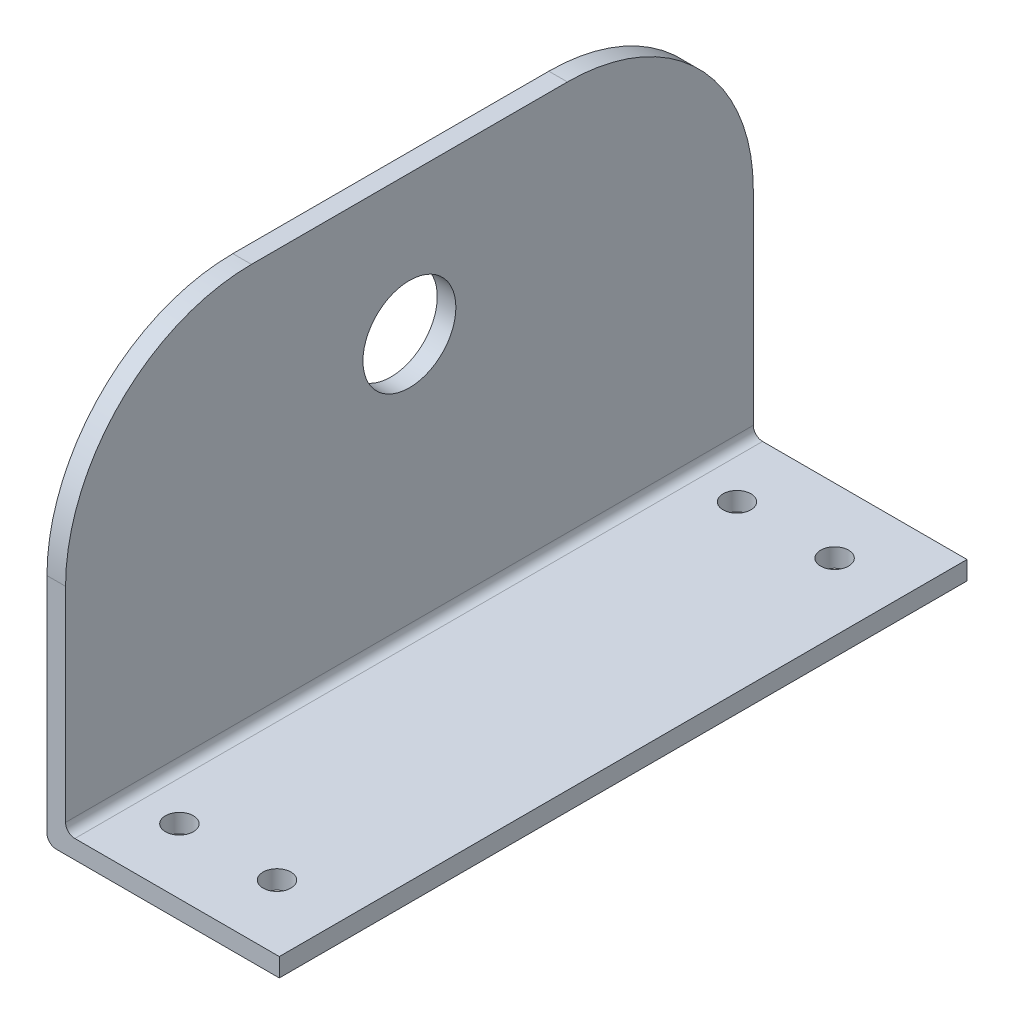
from build123d import *

# Parameters (mm, degrees)
SKETCH1_W           = 23
SKETCH1_H           = 74
SKETCH1_R           = 1.5
BOSS_EXTRUDE1_DEPTH = 2
SKETCH1_3_W         = 2
SKETCH1_3_H         = 74
BOSS_EXTRUDE2_DEPTH = 45
FILLET1_R           = 1
FILLET2_R           = 20
SKETCH2_R           = 5
CUT_EXTRUDE1_DEPTH  = 2


with BuildPart() as part:
    # Sketch1 → Boss-Extrude1 (new body)
    with BuildSketch(Plane(origin=(0, 0, 0), x_dir=(1, 0, 0), z_dir=(0, 1, 0))):
        with Locations((13.5, 37)):
            Rectangle(SKETCH1_W, SKETCH1_H)
        with Locations((7.25, 7)):
            Circle(SKETCH1_R, mode=Mode.SUBTRACT)
        with Locations((17.75, 7)):
            Circle(SKETCH1_R, mode=Mode.SUBTRACT)
        with Locations((7.25, 67)):
            Circle(SKETCH1_R, mode=Mode.SUBTRACT)
        with Locations((17.75, 67)):
            Circle(SKETCH1_R, mode=Mode.SUBTRACT)
    extrude(amount=BOSS_EXTRUDE1_DEPTH)

    # Sketch1_3 → Boss-Extrude2 (add)
    with BuildSketch(Plane(origin=(0, 0, 0), x_dir=(1, 0, 0), z_dir=(0, 1, 0))):
        with Locations((1, 37)):
            Rectangle(SKETCH1_3_W, SKETCH1_3_H)
    extrude(amount=BOSS_EXTRUDE2_DEPTH)

    # Fillet1
    fillet1_edges = [part.edges().sort_by_distance(p)[0] for p in [
        (0, 0, -37),
        (2, 2, -37),
    ]]
    fillet(fillet1_edges, radius=FILLET1_R)

    # Fillet2
    fillet2_edges = [part.edges().sort_by_distance(p)[0] for p in [
        (1, 45, -74),
        (1, 45, 0),
    ]]
    fillet(fillet2_edges, radius=FILLET2_R)

    # Sketch2 → Cut-Extrude1 (cut)
    with BuildSketch(Plane.ZY):
        with Locations((-37, 30)):
            Circle(SKETCH2_R)
    extrude(amount=-CUT_EXTRUDE1_DEPTH, mode=Mode.SUBTRACT)


solid = part.part
